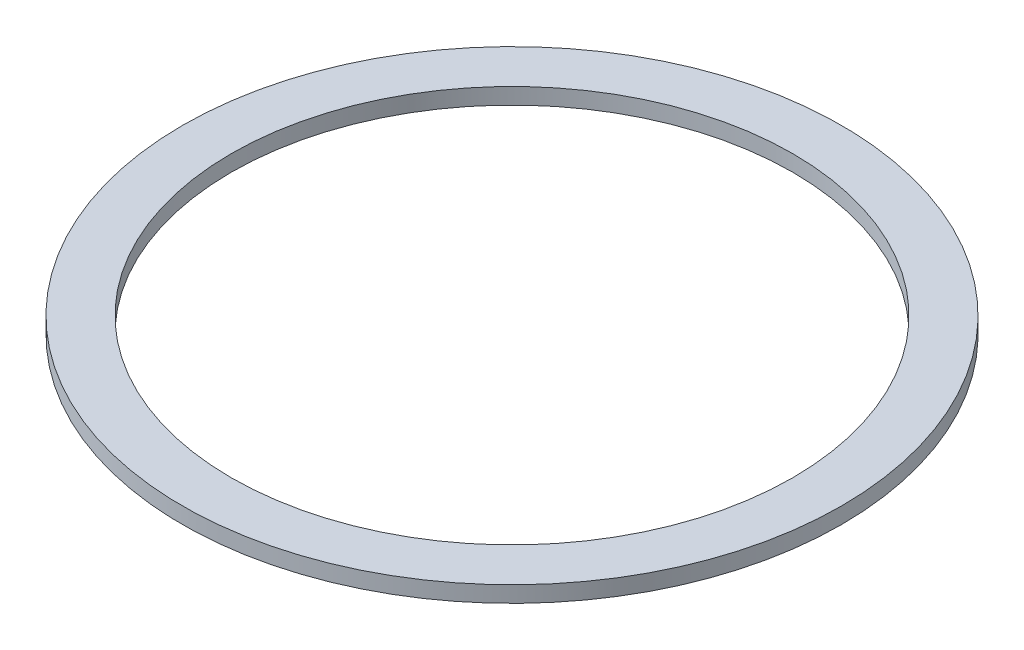
from build123d import *

# Parameters (mm, degrees)
RING_BASE_PROFILE_R        = 80.875
RING_BASE_PROFILE_R_2      = 70.375
RING_BASE_EXTRUSTION_DEPTH = 1.5
RING_LIP_PROFILE_W         = 0.8
RING_LIP_PROFILE_H         = 4
LED_CHANNEL_PROFILE_R      = 79.425
LED_CHANNEL_PROFILE_R_2    = 71.825
LED_CHANNEL_CUT_DEPTH      = 0.75


with BuildPart() as part:
    # Ring Base Profile → Ring Base Extrustion (new body)
    with BuildSketch(Plane(origin=(0, 0, 0), x_dir=(1, 0, 0), z_dir=(0, 1, 0))):
        with Locations(Location((0, 0, 0), (0, 0, 270))):
            Circle(RING_BASE_PROFILE_R)
        with Locations(Location((0, 0, 0), (0, 0, 270))):
            Circle(RING_BASE_PROFILE_R_2, mode=Mode.SUBTRACT)
    extrude(amount=RING_BASE_EXTRUSTION_DEPTH)

    # Ring Lip: sweep along a curve in space
    with BuildLine() as ring_lip_path:
        ThreePointArc((0, 1.5, 80.875), (57.187260928, 1.5, 57.187260928), (80.875, 1.5, 0))
        ThreePointArc((80.875, 1.5, 0), (57.187260928, 1.5, -57.187260928), (0, 1.5, -80.875))
        ThreePointArc((0, 1.5, -80.875), (-57.187260928, 1.5, -57.187260928), (-80.875, 1.5, 0))
        ThreePointArc((-80.875, 1.5, 0), (-57.187260928, 1.5, 57.187260928), (0, 1.5, 80.875))
    # Ring Lip Profile → Ring Lip (sweep)
    with BuildSketch(Plane.XY):
        with BuildLine():
            Line((-80.875, 1.5), (-80.875, -0.35))
            ThreePointArc((-80.875, -0.35), (-81.275, -0.75), (-80.875, -1.15))
            Line((-80.875, -1.15), (-80.875, -2.5))
            Line((-80.875, -2.5), (-81.675, -2.5))
            Line((-81.675, -2.5), (-81.675, 1.5))
            Line((-81.675, 1.5), (-80.875, 1.5))
        make_face()
        with Locations((-69.975, -0.5)):
            Rectangle(RING_LIP_PROFILE_W, RING_LIP_PROFILE_H)
    sweep(path=ring_lip_path.line)

    # LED Channel Profile → LED Channel Cut (cut)
    with BuildSketch(Plane.XZ):
        with Locations(Location((0, 0, 0), (0, 0, 270))):
            Circle(LED_CHANNEL_PROFILE_R)
        with Locations(Location((0, 0, 0), (0, 0, 270))):
            Circle(LED_CHANNEL_PROFILE_R_2, mode=Mode.SUBTRACT)
    extrude(amount=-LED_CHANNEL_CUT_DEPTH, mode=Mode.SUBTRACT)


solid = part.part
